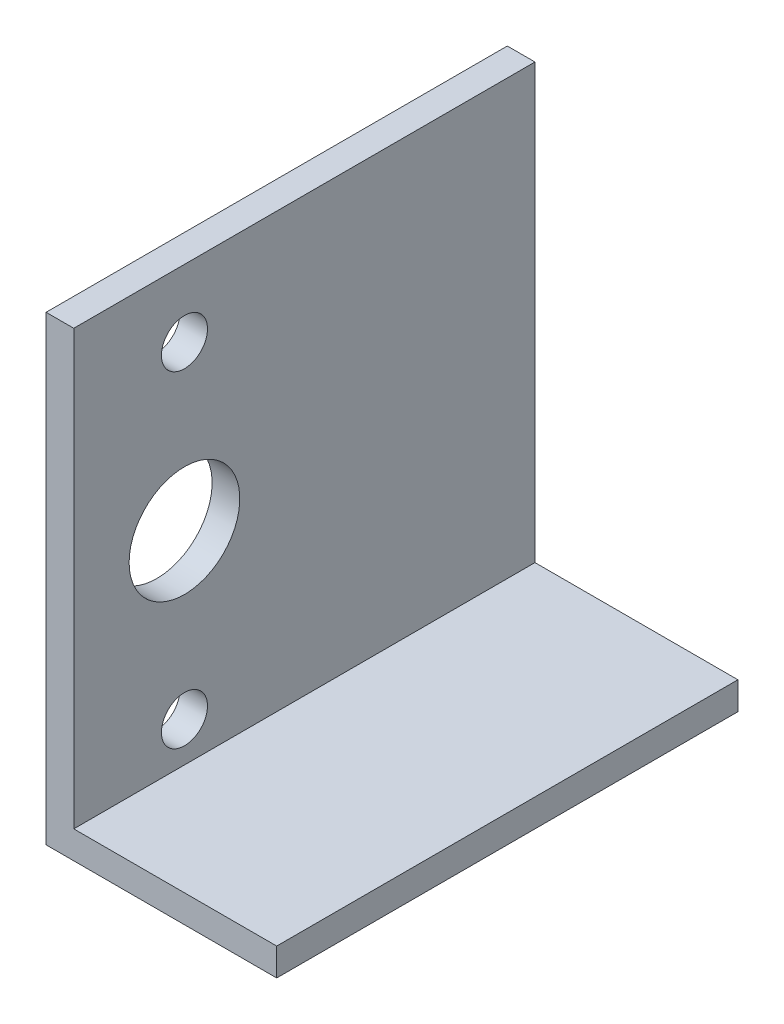
from build123d import *

# Parameters (mm, degrees)
SALIENTE_EXTRUIR1_DEPTH = 50
CROQUIS2_R              = 6
CROQUIS2_R_2            = 2.5
CORTAR_EXTRUIR1_DEPTH   = 3


with BuildPart() as part:
    # Croquis1 → Saliente-Extruir1 (new body)
    with BuildSketch(Plane.XY):
        Polygon((0, 50), (0, 0), (25, 0), (25, 3), (3, 3), (3, 50), align=None)
    extrude(amount=SALIENTE_EXTRUIR1_DEPTH)

    # Croquis2 → Cortar-Extruir1 (cut)
    with BuildSketch(Plane.ZY):
        with Locations((38, 25)):
            Circle(CROQUIS2_R)
        with Locations((38, 42.7)):
            Circle(CROQUIS2_R_2)
        with Locations((38, 7.3)):
            Circle(CROQUIS2_R_2)
    extrude(amount=-CORTAR_EXTRUIR1_DEPTH, mode=Mode.SUBTRACT)


solid = part.part
